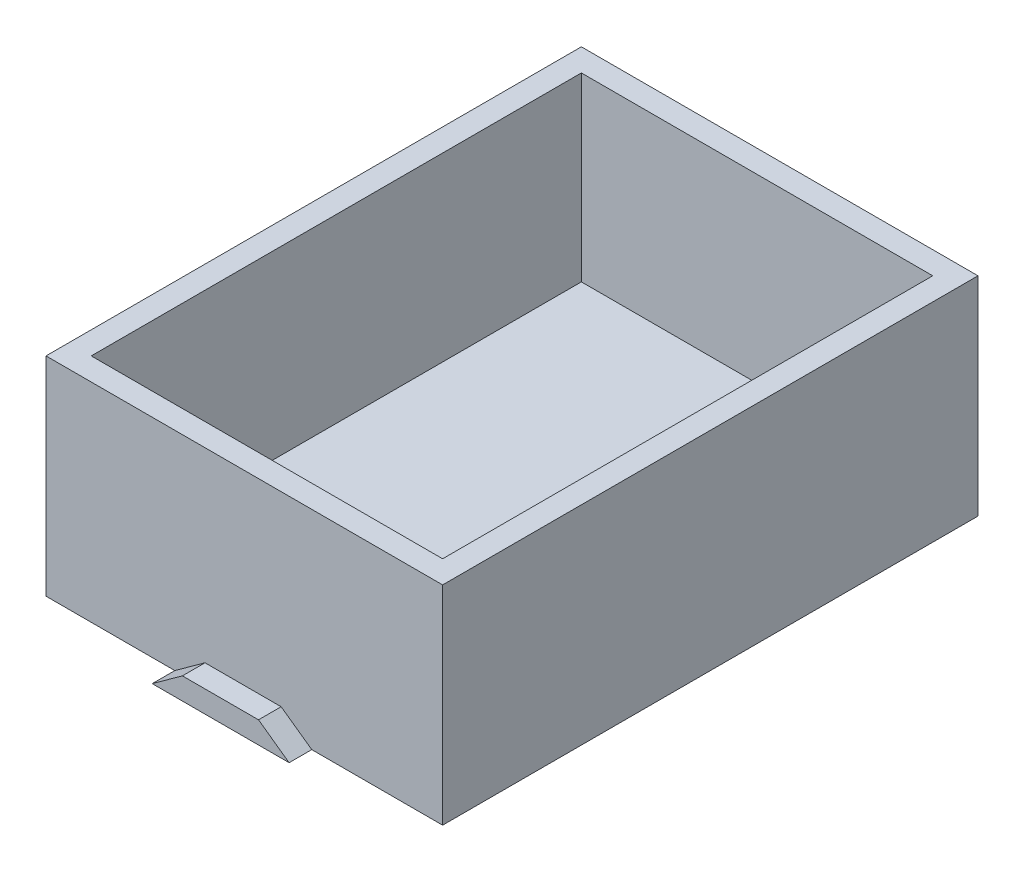
from build123d import *

# Parameters (mm, degrees)
SKETCH1_W           = 66.802
SKETCH1_H           = 35.052
BOSS_EXTRUDE1_DEPTH = 90.17
SKETCH2_W           = 59.182
SKETCH2_H           = 82.55
CUT_EXTRUDE2_DEPTH  = 30.48
BOSS_EXTRUDE2_DEPTH = 3.81


with BuildPart() as part:
    # Sketch1 → Boss-Extrude1 (new body)
    with BuildSketch(Plane.XY):
        with Locations((33.401, 17.526)):
            Rectangle(SKETCH1_W, SKETCH1_H)
    extrude(amount=-BOSS_EXTRUDE1_DEPTH)

    # Sketch2 → Cut-Extrude2 (cut)
    with BuildSketch(Plane(origin=(0, 35.052, 0), x_dir=(1, 0, 0), z_dir=(0, 1, 0))):
        with Locations((33.401, 45.085)):
            Rectangle(SKETCH2_W, SKETCH2_H)
    extrude(amount=-CUT_EXTRUDE2_DEPTH, mode=Mode.SUBTRACT)

    # Sketch3 → Boss-Extrude2 (add)
    with BuildSketch(Plane.XY):
        Polygon((26.781803903, 3.679405909), (21.695474271, 0), (33.226810629, 0), (44.758146987, 0), (39.602141606, 3.679405909), align=None)
    extrude(amount=BOSS_EXTRUDE2_DEPTH)


solid = part.part
